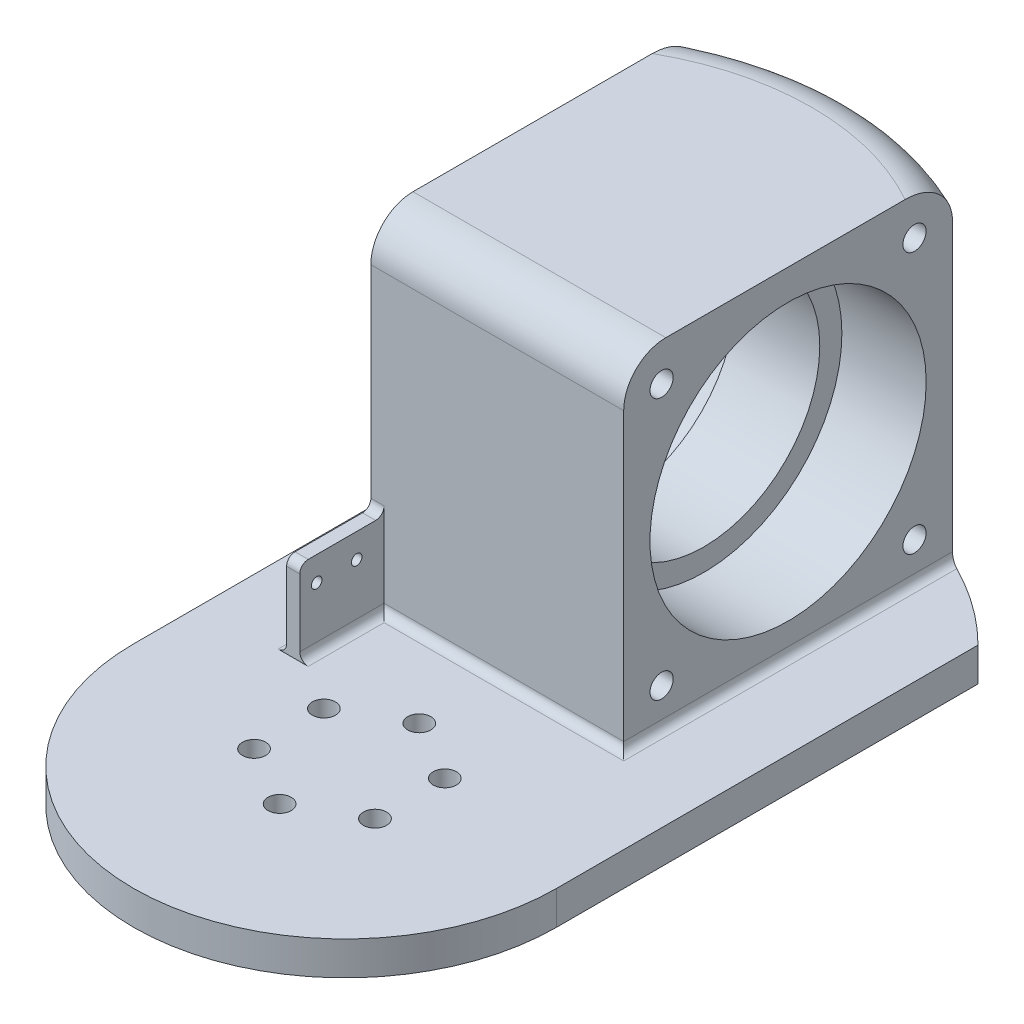
from build123d import *

# Parameters (mm, degrees)
SKETCH3_R               = 44.22
SKETCH3_R_2             = 2.7499999999999996
SKETCH3_R_3             = 2.75
SKETCH3_R_4             = 2.7499999999999982
BOSS_EXTRUDE1_DEPTH     = 1
BOSS_EXTRUDE2_DEPTH     = 8
SKETCH9_R               = 2.7499999999999996
SKETCH9_R_2             = 2.75
SKETCH9_R_3             = 2.7499999999999982
CUT_EXTRUDE2_DEPTH      = 20.000000000000004
BOSS_EXTRUDE3_DEPTH     = 80
CUT_EXTRUDE3_DEPTH      = 10
CUT_EXTRUDE3_DEPTH_BACK = 10
SKETCH12_R              = 32.774
SKETCH13_R              = 32.774
CUT_EXTRUDE4_DEPTH      = 20
SKETCH13_3_R            = 27.523999999999997
CUT_EXTRUDE5_DEPTH      = 66
BOSS_EXTRUDE4_DEPTH     = 20
SKETCH3_4_R             = 44.22
SKETCH3_4_R_2           = 2.7499999999999996
SKETCH3_4_R_3           = 2.75
SKETCH3_4_R_4           = 2.7499999999999982
CUT_EXTRUDE6_DEPTH      = 1
SKETCH15_R              = 1.2500000000000013
CUT_EXTRUDE7_DEPTH      = 10
SKETCH17_R              = 2.7499999999999964
SKETCH17_R_2            = 2.7500000000000298
SKETCH17_R_3            = 2.7500000000000013
SKETCH17_R_4            = 2.7500000000000178
CUT_EXTRUDE8_DEPTH      = 83.00000000000001
SKETCH18_R              = 6.250000000000003
SKETCH18_R_2            = 6.250000000000001
SKETCH18_R_3            = 6.250000000000002
CUT_EXTRUDE9_DEPTH      = 5.5
FILLET1_R               = 10
FILLET2_R               = 2
FILLET3_R               = 2


with BuildPart() as part:
    # Sketch3 → Boss-Extrude1 (new body)
    with BuildSketch(Plane(origin=(0, 0, 0), x_dir=(1, 0, 0), z_dir=(0, 1, 0))):
        with Locations((-1.3e-16, 1.0493371124306385)):
            Circle(SKETCH3_R)
        with Locations((-1.1596e-13, 17.619337112430635)):
            Circle(SKETCH3_R_2, mode=Mode.SUBTRACT)
        with Locations((14.350040940708112, 9.334337112430703)):
            Circle(SKETCH3_R_3, mode=Mode.SUBTRACT)
        with Locations((14.350040940708167, -7.235662887569328)):
            Circle(SKETCH3_R_3, mode=Mode.SUBTRACT)
        with Locations((0, -15.520662887569364)):
            Circle(SKETCH3_R_3, mode=Mode.SUBTRACT)
        with Locations((-14.350040940708052, -7.235662887569527)):
            Circle(SKETCH3_R_4, mode=Mode.SUBTRACT)
        with Locations((-14.350040940708224, 9.334337112430505)):
            Circle(SKETCH3_R_4, mode=Mode.SUBTRACT)
    extrude(amount=BOSS_EXTRUDE1_DEPTH)

    # Sketch4 → Boss-Extrude2 (add)
    with BuildSketch(Plane(origin=(0, 1, 0), x_dir=(1, 0, 0), z_dir=(0, 1, 0))):
        with BuildLine():
            Line((-50.22, 0), (-50.22, 100))
            ThreePointArc((-50.22, 100), (4.35e-15, 120.80180510237683), (50.22, 100))
            Line((50.22, 100), (50.22, 0))
            ThreePointArc((50.22, 0), (3.08e-15, -50.22), (-50.22, 0))
        make_face()
    extrude(amount=BOSS_EXTRUDE2_DEPTH)

    # Sketch9 → Cut-Extrude2 (cut)
    with BuildSketch(Plane.XZ):
        with Locations((0, 15.520662887569364)):
            Circle(SKETCH9_R)
        with Locations((14.350040940708167, 7.235662887569328)):
            Circle(SKETCH9_R_2)
        with Locations((14.350040940708112, -9.334337112430703)):
            Circle(SKETCH9_R_2)
        with Locations((-1.1596e-13, -17.619337112430635)):
            Circle(SKETCH9_R)
        with Locations((-14.350040940708224, -9.334337112430505)):
            Circle(SKETCH9_R_3)
        with Locations((-14.350040940708052, 7.235662887569527)):
            Circle(SKETCH9_R_3)
    extrude(amount=-CUT_EXTRUDE2_DEPTH, mode=Mode.SUBTRACT)

    # Sketch11 → Boss-Extrude3 (add)
    with BuildSketch(Plane(origin=(0, 9.000000000000002, 0), x_dir=(1, 0, 0), z_dir=(0, 1, 0))):
        with BuildLine():
            Line((-6.94e-15, 36.135374780750475), (-30.00000000000018, 36.135374780750475))
            Line((-30.00000000000018, 36.135374780750475), (-30.000000000000174, 114.15465961075047))
            ThreePointArc((-30.000000000000174, 114.15465961075047), (-1.9981e-13, 120.8018051023768), (29.999999999999822, 114.15465961075066))
            Line((29.999999999999822, 114.15465961075066), (29.999999999999837, 36.135374780750475))
            Line((29.999999999999837, 36.135374780750475), (-6.94e-15, 36.135374780750475))
        make_face()
    extrude(amount=BOSS_EXTRUDE3_DEPTH)

    # Sketch12 → Cut-Extrude3 (cut, two sides: drawn at the far end of the back side and taken through both)
    with BuildSketch(Plane.ZY.offset(20).offset(-CUT_EXTRUDE3_DEPTH_BACK)):
        with Locations((-75.14437478075048, 49)):
            Circle(SKETCH12_R)
    extrude(amount=CUT_EXTRUDE3_DEPTH + CUT_EXTRUDE3_DEPTH_BACK, mode=Mode.SUBTRACT)

    # Sketch13 → Cut-Extrude4 (cut)
    with BuildSketch(Plane(origin=(29.999999999999844, 0, -5.34e-15), x_dir=(-1.8e-16, 0, -1), z_dir=(1, 0, -1.8e-16))):
        with Locations((75.14501719575057, 49)):
            Circle(SKETCH13_R)
    extrude(amount=-CUT_EXTRUDE4_DEPTH, mode=Mode.SUBTRACT)

    # Sketch13_3 → Cut-Extrude5 (cut)
    with BuildSketch(Plane(origin=(29.999999999999844, 0, -5.34e-15), x_dir=(-1.8e-16, 0, -1), z_dir=(1, 0, -1.8e-16))):
        with Locations((75.14501719575057, 49)):
            Circle(SKETCH13_3_R)
    extrude(amount=-CUT_EXTRUDE5_DEPTH, mode=Mode.SUBTRACT)

    # Sketch14 → Boss-Extrude4 (add)
    with BuildSketch(Plane(origin=(0, 9.000000000000002, 0), x_dir=(1, 0, 0), z_dir=(0, 1, 0))):
        Polygon((-30.00000000000018, 36.135374780750475), (-26.865006521544387, 36.135374780750475), (-26.865006521544384, 16.135374780750475), (-30.000000000000178, 16.135374780750475), align=None)
    extrude(amount=BOSS_EXTRUDE4_DEPTH)

    # Sketch3_4 → Cut-Extrude6 (cut)
    with BuildSketch(Plane(origin=(0, 0, 0), x_dir=(1, 0, 0), z_dir=(0, 1, 0))):
        with Locations((-1.3e-16, 1.0493371124306385)):
            Circle(SKETCH3_4_R)
        with Locations((-1.1596e-13, 17.619337112430635)):
            Circle(SKETCH3_4_R_2, mode=Mode.SUBTRACT)
        with Locations((14.350040940708112, 9.334337112430703)):
            Circle(SKETCH3_4_R_3, mode=Mode.SUBTRACT)
        with Locations((14.350040940708167, -7.235662887569328)):
            Circle(SKETCH3_4_R_3, mode=Mode.SUBTRACT)
        with Locations((0, -15.520662887569364)):
            Circle(SKETCH3_4_R_3, mode=Mode.SUBTRACT)
        with Locations((-14.350040940708052, -7.235662887569527)):
            Circle(SKETCH3_4_R_4, mode=Mode.SUBTRACT)
        with Locations((-14.350040940708224, 9.334337112430505)):
            Circle(SKETCH3_4_R_4, mode=Mode.SUBTRACT)
    extrude(amount=CUT_EXTRUDE6_DEPTH, mode=Mode.SUBTRACT)

    # Sketch15 → Cut-Extrude7 (cut)
    with BuildSketch(Plane.ZY.offset(30.000000000000185)):
        with Locations((-20.13537478075047, 23.20152903851172)):
            Circle(SKETCH15_R)
        with Locations((-29.63537478075047, 23.20152903851172)):
            Circle(SKETCH15_R)
    extrude(amount=-CUT_EXTRUDE7_DEPTH, mode=Mode.SUBTRACT)

    # Sketch17 → Cut-Extrude8 (cut)
    with BuildSketch(Plane(origin=(29.999999999999844, 0, -5.34e-15), x_dir=(-1.8e-16, 0, -1), z_dir=(1, 0, -1.8e-16))):
        with Locations((45.135374780750475, 80)):
            Circle(SKETCH17_R)
        with Locations((105.15465961075067, 80.00000000000001)):
            Circle(SKETCH17_R_2)
        with Locations((45.135374780750475, 18.000000000000004)):
            Circle(SKETCH17_R_3)
        with Locations((105.15465961075066, 17.99999999999999)):
            Circle(SKETCH17_R_4)
    extrude(amount=-CUT_EXTRUDE8_DEPTH, mode=Mode.SUBTRACT)

    # Sketch18 → Cut-Extrude9 (cut)
    with BuildSketch(Plane.ZY.offset(30.000000000000185)):
        with Locations((-105.15465961075064, 80)):
            Circle(SKETCH18_R)
        with Locations((-45.13537478075047, 80)):
            Circle(SKETCH18_R)
        with Locations((-45.135374780750475, 18.000000000000004)):
            Circle(SKETCH18_R_2)
        with Locations((-105.15465961075064, 18.000000000000004)):
            Circle(SKETCH18_R_3)
    extrude(amount=-CUT_EXTRUDE9_DEPTH, mode=Mode.SUBTRACT)

    # Fillet1
    fillet1_edges = [part.edges().sort_by_distance(p)[0] for p in [
        (-1.9451e-13, 89, -120.80180510237682),
        (-1.7053e-13, 89, -36.135374780750475),
    ]]
    fillet(fillet1_edges, radius=FILLET1_R)

    # Fillet2
    fillet2_edges = [part.edges().sort_by_distance(p)[0] for p in [
        (-26.865006521544387, 9.000000000000002, -26.135374780750475),
        (1.567496739227721, 9.000000000000002, -36.135374780750475),
        (29.99999999999983, 9.000000000000002, -75.14501719575057),
        (-30.000000000000178, 9.000000000000002, -65.14501719575048),
    ]]
    fillet(fillet2_edges, radius=FILLET2_R)

    # Fillet3
    fillet3_edges = [part.edges().sort_by_distance(p)[0] for p in [
        (-28.432503260772286, 29, -36.135374780750475),
        (-28.43250326077228, 29, -16.135374780750475),
    ]]
    fillet(fillet3_edges, radius=FILLET3_R)


solid = part.part
